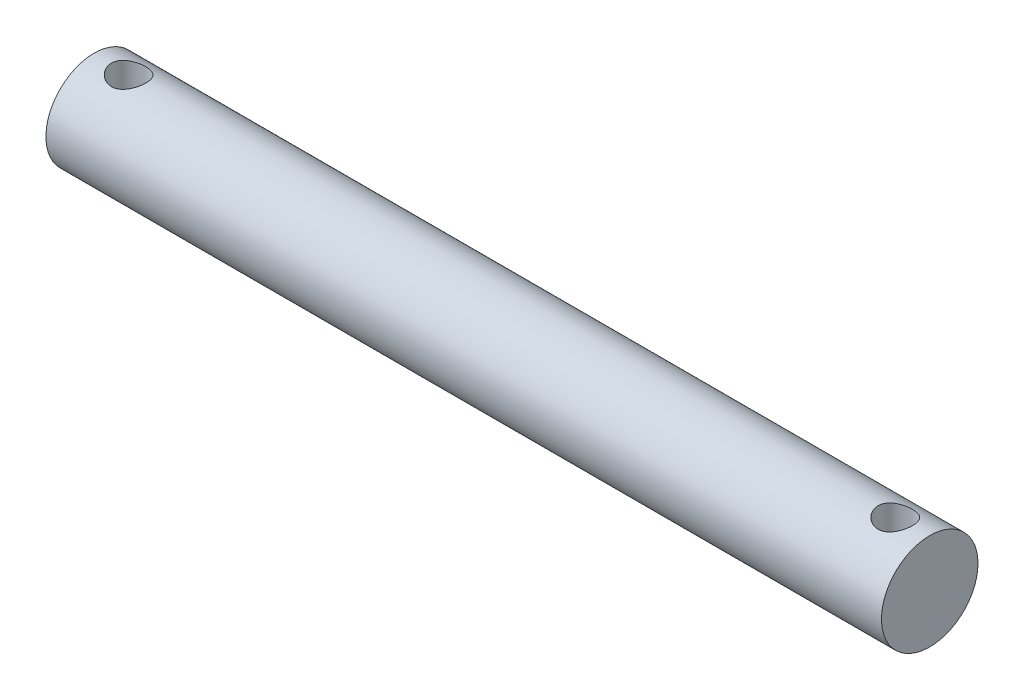
from build123d import *

# Parameters (mm, degrees)
SKETCH1_R               = 4.445
BOSS_EXTRUDE1_DEPTH     = 38.481
SKETCH2_R               = 1.5875
CUT_EXTRUDE1_DEPTH      = 5.445
CUT_EXTRUDE1_DEPTH_BACK = 5.445


with BuildPart() as part:
    # Sketch1 → Boss-Extrude1 (new body, symmetric)
    with BuildSketch(Plane(origin=(0, 0, 0), x_dir=(0, 0, -1), z_dir=(1, 0, 0))):
        Circle(SKETCH1_R)
    extrude(amount=BOSS_EXTRUDE1_DEPTH, both=True)

    # Sketch2 → Cut-Extrude1 (cut, two sides)
    with BuildSketch(Plane(origin=(0, 0, 0), x_dir=(1, 0, 0), z_dir=(0, 1, 0))) as cut_extrude1_sk:
        with Locations((-35.306, 0)):
            Circle(SKETCH2_R)
        with Locations((35.306, 0)):
            Circle(SKETCH2_R)
    extrude(amount=CUT_EXTRUDE1_DEPTH, mode=Mode.SUBTRACT)
    extrude(cut_extrude1_sk.sketch, amount=-CUT_EXTRUDE1_DEPTH_BACK, mode=Mode.SUBTRACT)


solid = part.part
